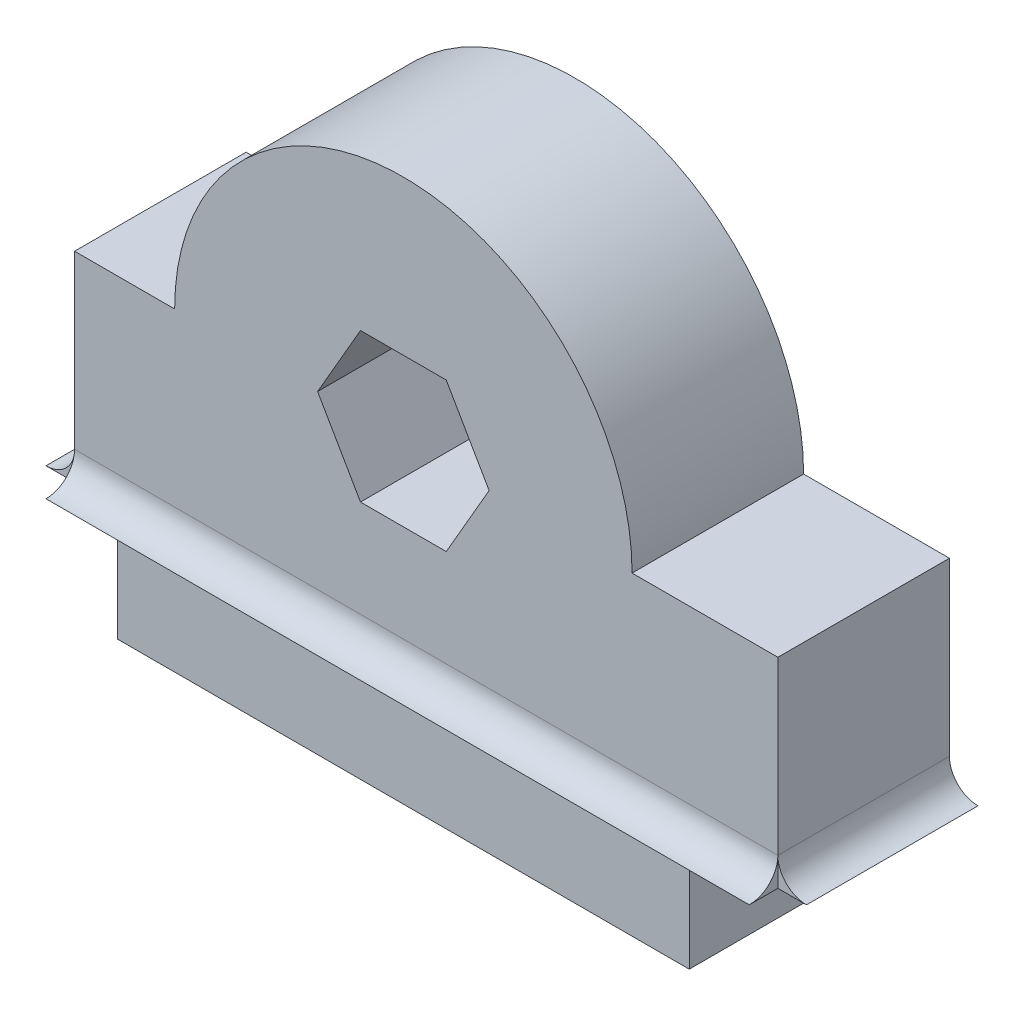
from build123d import *

# Parameters (mm, degrees)
BOSS_EXTRUDE1_DEPTH = 6
BOSS_EXTRUDE2_DEPTH = 24.6
BOSS_EXTRUDE3_DEPTH = 6


with BuildPart() as part:
    # Sketch1 → Boss-Extrude1 (new body)
    with BuildSketch(Plane.XY):
        with BuildLine():
            Line((0, 0), (20, 0))
            Line((20, 0), (20, 4))
            Line((20, 4), (23.1, 4))
            Line((23.1, 4), (23.1, 11))
            Line((23.1, 11), (18, 11))
            ThreePointArc((18, 11), (10, 19), (2, 11))
            Line((2, 11), (-1.5, 11))
            Line((-1.5, 11), (-1.5, 4))
            Line((-1.5, 4), (0, 4))
            Line((0, 4), (0, 0))
        make_face()
        Polygon((13, 11), (11.5, 13.598076211), (8.5, 13.598076211), (7, 11), (8.5, 8.401923789), (11.5, 8.401923789), align=None, mode=Mode.SUBTRACT)
    extrude(amount=BOSS_EXTRUDE1_DEPTH)

    # Sketch2 → Boss-Extrude2 (add)
    with BuildSketch(Plane.ZY.offset(1.5)):
        with BuildLine():
            Line((6, 4), (6, 5))
            ThreePointArc((6, 5), (6.292893219, 4.292893219), (7, 4))
            Line((7, 4), (6, 4))
        make_face()
    extrude(amount=-BOSS_EXTRUDE2_DEPTH)

    # Sketch4 → Boss-Extrude3 (add)
    with BuildSketch(Plane.XY.offset(6)):
        with BuildLine():
            Line((23.1, 4), (23.1, 5))
            ThreePointArc((23.1, 5), (23.392893219, 4.292893219), (24.1, 4))
            Line((24.1, 4), (23.1, 4))
        make_face()
        with BuildLine():
            Line((-1.5, 4), (-2.5, 4))
            ThreePointArc((-2.5, 4), (-1.792893219, 4.292893219), (-1.5, 5))
            Line((-1.5, 5), (-1.5, 4))
        make_face()
    extrude(amount=-BOSS_EXTRUDE3_DEPTH)


solid = part.part
